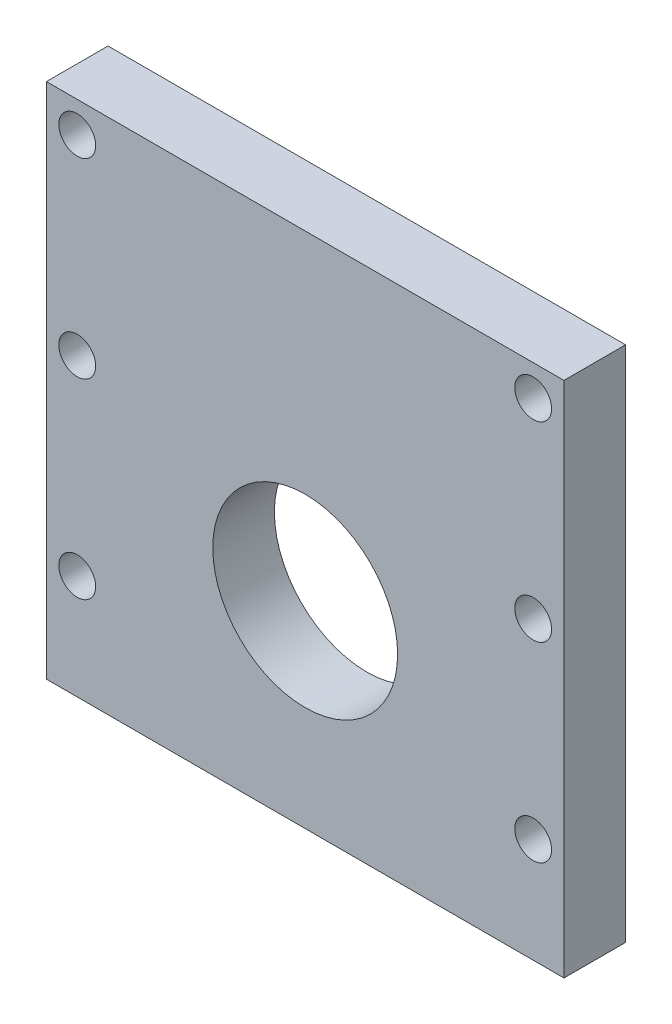
from build123d import *

# Parameters (mm, degrees)
SKETCH1_W                 = 53.34
SKETCH1_H                 = 53.34
BOSS_EXTRUDE1_DEPTH       = 6.35
SKETCH2_R                 = 9.525
CUT_EXTRUDE1_DEPTH        = 1
CUT_EXTRUDE1_DEPTH_BACK   = 7.35
F_6_CLEARANCE_HOLE1_D     = 3.7973
F_6_CLEARANCE_HOLE1_DEPTH = 6.35


with BuildPart() as part:
    # Sketch1 → Boss-Extrude1 (new body)
    with BuildSketch(Plane.XY):
        with Locations((26.67, 26.67)):
            Rectangle(SKETCH1_W, SKETCH1_H)
    extrude(amount=BOSS_EXTRUDE1_DEPTH)

    # Sketch2 → Cut-Extrude1 (cut, two sides)
    with BuildSketch(Plane.XY.offset(6.35)) as cut_extrude1_sk:
        with Locations((26.67, 20.32)):
            Circle(SKETCH2_R)
    extrude(amount=CUT_EXTRUDE1_DEPTH, mode=Mode.SUBTRACT)
    extrude(cut_extrude1_sk.sketch, amount=-CUT_EXTRUDE1_DEPTH_BACK, mode=Mode.SUBTRACT)

    # #6 Clearance Hole1
    with Locations(Plane.XY.offset(6.35)):
        with Locations((3.175, 50.165), (50.165, 50.165), (50.165, 10.795), (3.175, 10.795), (3.175, 30.48), (50.165, 30.48)):
            Hole(F_6_CLEARANCE_HOLE1_D / 2, depth=F_6_CLEARANCE_HOLE1_DEPTH)


solid = part.part
